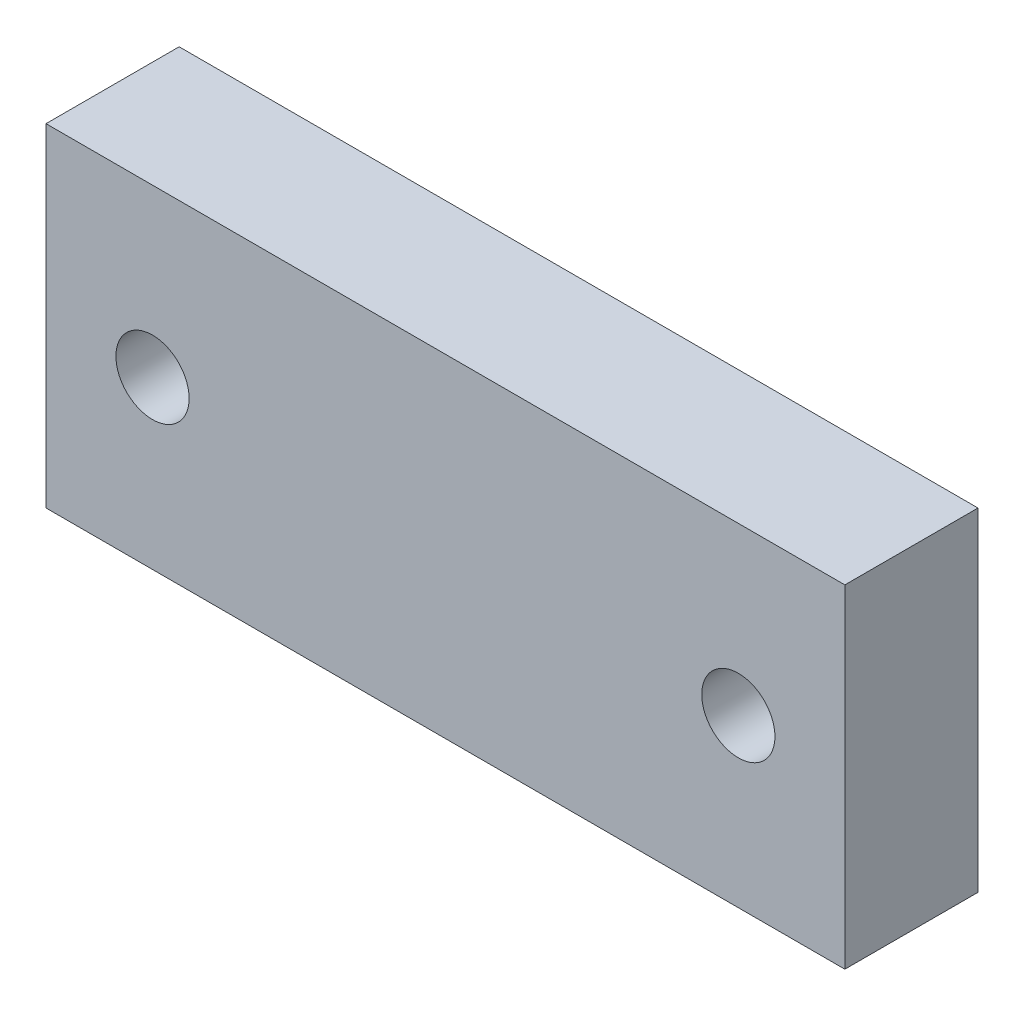
from build123d import *

# Parameters (mm, degrees)
SKETCH_1_W      = 60
SKETCH_1_H      = 25
SKETCH_1_R      = 2.75
EXTRUDE_1_DEPTH = 10


with BuildPart() as part:
    # 草圖1 → 填料-伸長1 (new body)
    with BuildSketch(Plane.XY):
        with Locations((16.99607615, 5.50121042)):
            Rectangle(SKETCH_1_W, SKETCH_1_H)
        with Locations((-5.00392385, 5.50121042)):
            Circle(SKETCH_1_R, mode=Mode.SUBTRACT)
        with Locations((38.99607615, 5.50121042)):
            Circle(SKETCH_1_R, mode=Mode.SUBTRACT)
    extrude(amount=EXTRUDE_1_DEPTH)


solid = part.part
